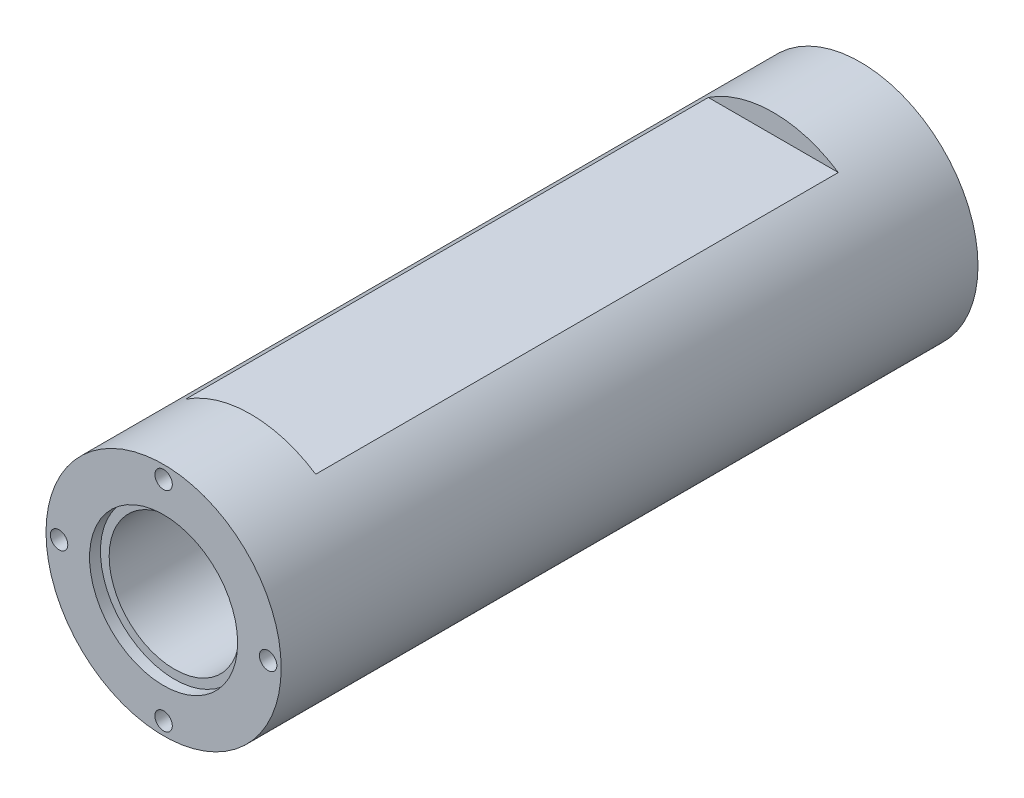
from build123d import *

# Parameters (mm, degrees)
ESQUISSE1_R           = 27
ESQUISSE1_R_2         = 15
EXTRUSION1_DEPTH      = 160
ESQUISSE2_R           = 2
EXTRUSION2_DEPTH      = 15
ESQUISSE3_R           = 2
EXTRUSION3_DEPTH      = 15
ESQUISSE4_R           = 17
ESQUISSE4_R_2         = 15
EXTRUSION4_DEPTH      = 2.5
ESQUISSE5_R           = 17
ESQUISSE5_R_2         = 15
EXTRUSION5_DEPTH      = 2.5
ESQUISSE6_W           = 120
ESQUISSE6_H           = 4.5
ESQUISSE6_H_2         = 6
EXTRUSION6_DEPTH      = 28
EXTRUSION6_DEPTH_BACK = 28


with BuildPart() as part:
    # Esquisse1 → Extrusion1 (new body)
    with BuildSketch(Plane.XY):
        Circle(ESQUISSE1_R)
        Circle(ESQUISSE1_R_2, mode=Mode.SUBTRACT)
    extrude(amount=EXTRUSION1_DEPTH)

    # Esquisse2 → Extrusion2 (cut)
    with BuildSketch(Plane.XY.offset(160)):
        with Locations((0, 24)):
            Circle(ESQUISSE2_R)
        with Locations((24, 0)):
            Circle(ESQUISSE2_R)
        with Locations((0, -24)):
            Circle(ESQUISSE2_R)
        with Locations((-24, 0)):
            Circle(ESQUISSE2_R)
    extrude(amount=-EXTRUSION2_DEPTH, mode=Mode.SUBTRACT)

    # Esquisse3 → Extrusion3 (cut)
    with BuildSketch(Plane(origin=(0, 0, 0), x_dir=(-1, 0, 0), z_dir=(0, 0, -1))):
        with Locations((0, 24)):
            Circle(ESQUISSE3_R)
        with Locations((24, 0)):
            Circle(ESQUISSE3_R)
        with Locations((0, -24)):
            Circle(ESQUISSE3_R)
        with Locations((-24, 0)):
            Circle(ESQUISSE3_R)
    extrude(amount=-EXTRUSION3_DEPTH, mode=Mode.SUBTRACT)

    # Esquisse4 → Extrusion4 (cut)
    with BuildSketch(Plane.XY.offset(160)):
        Circle(ESQUISSE4_R)
        Circle(ESQUISSE4_R_2, mode=Mode.SUBTRACT)
    extrude(amount=-EXTRUSION4_DEPTH, mode=Mode.SUBTRACT)

    # Esquisse5 → Extrusion5 (cut)
    with BuildSketch(Plane(origin=(0, 0, 0), x_dir=(-1, 0, 0), z_dir=(0, 0, -1))):
        Circle(ESQUISSE5_R)
        Circle(ESQUISSE5_R_2, mode=Mode.SUBTRACT)
    extrude(amount=-EXTRUSION5_DEPTH, mode=Mode.SUBTRACT)

    # Esquisse6 → Extrusion6 (cut, two sides)
    with BuildSketch(Plane(origin=(0, 0, 0), x_dir=(0, 0, -1), z_dir=(1, 0, 0))) as extrusion6_sk:
        with Locations((-80, 24.75)):
            Rectangle(ESQUISSE6_W, ESQUISSE6_H)
        with Locations((-80, -24)):
            Rectangle(ESQUISSE6_W, ESQUISSE6_H_2)
    extrude(amount=EXTRUSION6_DEPTH, mode=Mode.SUBTRACT)
    extrude(extrusion6_sk.sketch, amount=-EXTRUSION6_DEPTH_BACK, mode=Mode.SUBTRACT)


solid = part.part
